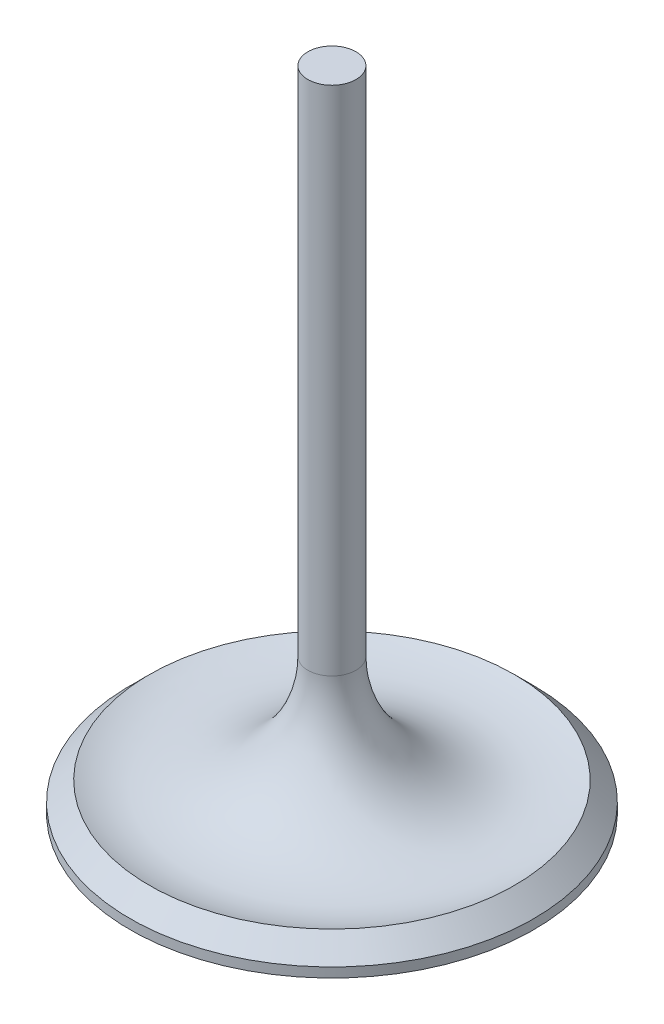
from build123d import *


with BuildPart() as part:
    # Sketch1 → Revolve1 (revolve)
    with BuildSketch(Plane.XY):
        with BuildLine():
            Line((0, 0), (0, 85.55))
            Line((0, 85.55), (3.18, 85.55))
            Line((3.18, 85.55), (3.18, 17.954698654))
            ThreePointArc((3.18, 17.954698654), (9.896609701, 5.315721242), (24.13, 3.81))
            Line((24.13, 3.81), (26.67, 1.27))
            Line((26.67, 1.27), (26.67, 0))
            Line((26.67, 0), (0, 0))
        make_face()
    revolve(axis=Axis((0, 0, 0), (0, 1, 0)))


solid = part.part
